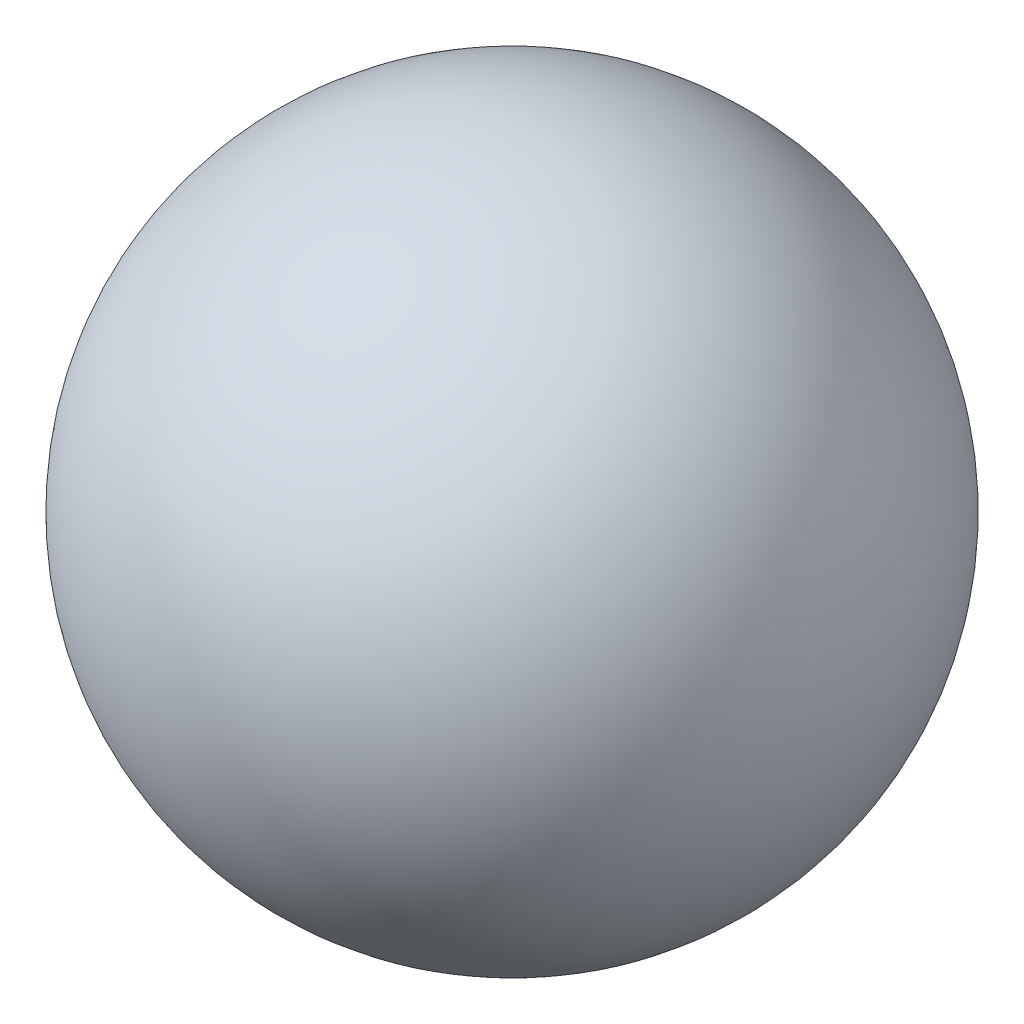
from build123d import *


with BuildPart() as part:
    # Croquis1 → Revolución1 (revolve)
    with BuildSketch(Plane.XY):
        with BuildLine():
            Line((-52.019276555, 52.744416346), (-52.019276555, 39.244416346))
            ThreePointArc((-52.019276555, 39.244416346), (-45.269276555, 45.994416346), (-52.019276555, 52.744416346))
        make_face()
    revolve(axis=Axis((-52.019276555, 52.744416346, 0), (0, -1, 0)))


solid = part.part
